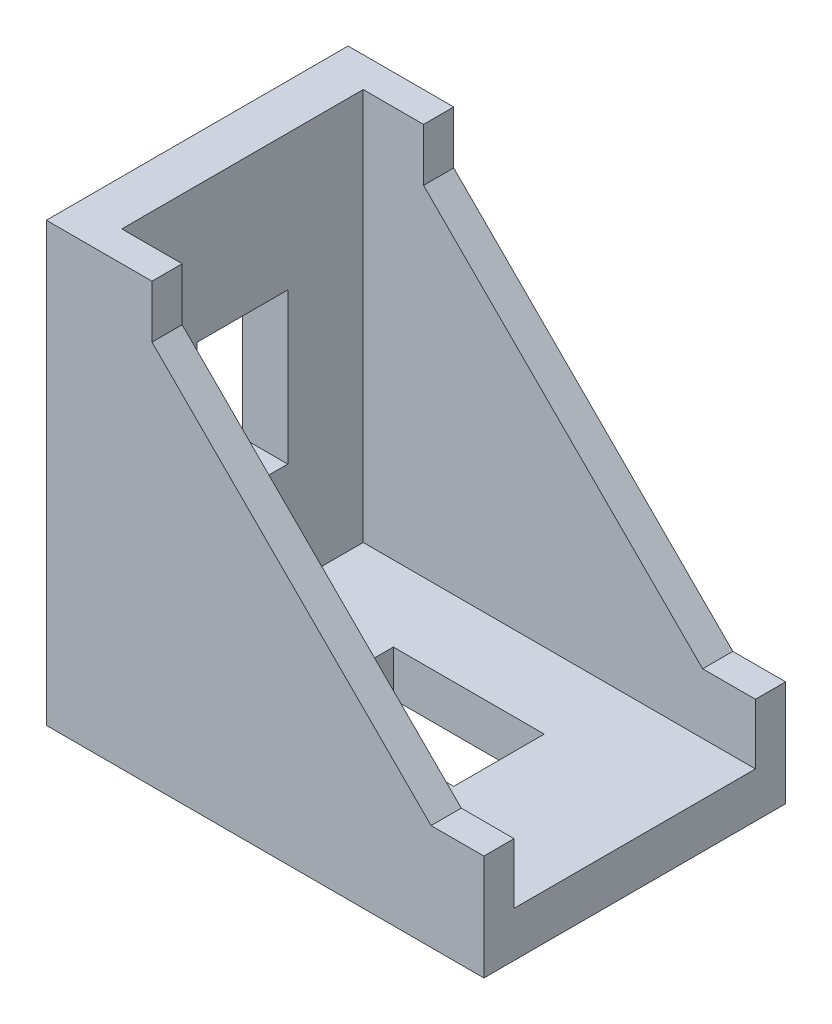
from build123d import *

# Parameters (mm, degrees)
SKETCH1_W           = 29
SKETCH1_H           = 29
BOSS_EXTRUDE1_DEPTH = 20
SKETCH2_W           = 26
SKETCH2_H           = 16
CUT_EXTRUDE1_DEPTH  = 26
CUT_EXTRUDE2_DEPTH  = 21
SKETCH4_W           = 10
SKETCH4_H           = 6
CUT_EXTRUDE3_DEPTH  = 30
SKETCH5_W           = 6
SKETCH5_H           = 10
CUT_EXTRUDE4_DEPTH  = 30


with BuildPart() as part:
    # Sketch1 → Boss-Extrude1 (new body)
    with BuildSketch(Plane.XY):
        Rectangle(SKETCH1_W, SKETCH1_H)
    extrude(amount=BOSS_EXTRUDE1_DEPTH)

    # Sketch2 → Cut-Extrude1 (cut)
    with BuildSketch(Plane(origin=(0, 14.5, 0), x_dir=(1, 0, 0), z_dir=(0, 1, 0))):
        with Locations((1.5, -10)):
            Rectangle(SKETCH2_W, SKETCH2_H)
    extrude(amount=-CUT_EXTRUDE1_DEPTH, mode=Mode.SUBTRACT)

    # Sketch3 → Cut-Extrude2 (cut, through all)
    with BuildSketch(Plane.XY.offset(20)):
        Polygon((-7.5, 14.5), (-7.5, 11), (11, -7.5), (14.5, -7.5), (14.5, 14.5), align=None)
    extrude(amount=-CUT_EXTRUDE2_DEPTH, mode=Mode.SUBTRACT)

    # Sketch4 → Cut-Extrude3 (cut, through all)
    with BuildSketch(Plane.XZ.offset(14.5)):
        with Locations((0.5, 10)):
            Rectangle(SKETCH4_W, SKETCH4_H)
    extrude(amount=-CUT_EXTRUDE3_DEPTH, mode=Mode.SUBTRACT)

    # Sketch5 → Cut-Extrude4 (cut, through all)
    with BuildSketch(Plane.ZY.offset(14.5)):
        with Locations((10, 0.5)):
            Rectangle(SKETCH5_W, SKETCH5_H)
    extrude(amount=-CUT_EXTRUDE4_DEPTH, mode=Mode.SUBTRACT)


solid = part.part
